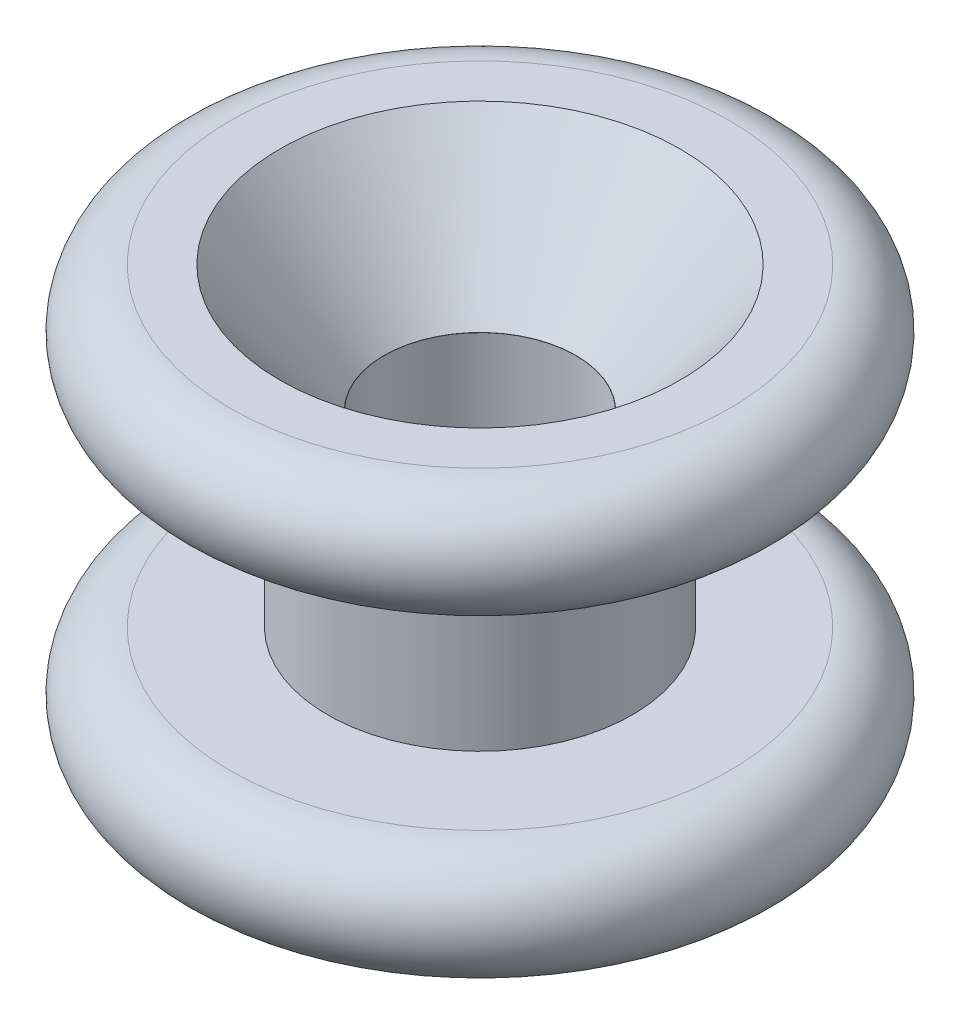
from build123d import *


with BuildPart() as part:
    # Sketch2 → Revolve1 (revolve)
    with BuildSketch(Plane.XY):
        with BuildLine():
            Line((2.4967819, -5.588), (2.4967819, 5.588))
            Line((2.4967819, 5.588), (6.5024, 5.588))
            ThreePointArc((6.5024, 5.588), (8.001, 4.0894), (6.5024, 2.5908))
            Line((6.5024, 2.5908), (3.9751, 2.5908))
            Line((3.9751, 2.5908), (3.9751, -2.5908))
            Line((3.9751, -2.5908), (6.5024, -2.5908))
            ThreePointArc((6.5024, -2.5908), (8.001, -4.0894), (6.5024, -5.588))
            Line((6.5024, -5.588), (2.4967819, -5.588))
        make_face()
    revolve(axis=Axis((0, 0, 0), (0, 1, 0)))

    # Sketch3 → Cut-Revolve1 (revolve, cut)
    with BuildSketch(Plane.XY):
        Polygon((0, 5.588), (5.2197, 5.588), (2.5019, 2.286), (0, 2.286), align=None)
    revolve(axis=Axis((0, 2.286, 0), (0, 1, 0)), mode=Mode.SUBTRACT)


solid = part.part
